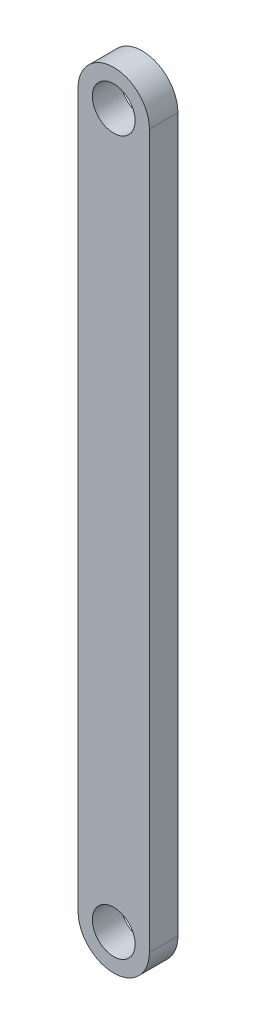
from build123d import *

# Parameters (mm, degrees)
Y_KSEKLIK_EKSTR_ZYON1_DEPTH = 2
IZIM3_R                     = 1.5
KES_EKSTR_ZYON1_DEPTH       = 3
IZIM5_R                     = 1.5
KES_EKSTR_ZYON2_DEPTH       = 2


with BuildPart() as part:
    # Çizim1 → Yükseklik-Ekstrüzyon1 (new body)
    with BuildSketch(Plane.XY):
        with BuildLine():
            Line((-2.5, 50), (-2.5, 0))
            ThreePointArc((-2.5, 0), (0, -2.5), (2.5, 0))
            Line((2.5, 0), (2.5, 50))
            ThreePointArc((2.5, 50), (0, 52.5), (-2.5, 50))
        make_face()
    extrude(amount=-Y_KSEKLIK_EKSTR_ZYON1_DEPTH)

    # Çizim3 → Kes-Ekstrüzyon1 (cut, through all)
    with BuildSketch(Plane.XY):
        Circle(IZIM3_R)
    extrude(amount=-KES_EKSTR_ZYON1_DEPTH, mode=Mode.SUBTRACT)

    # Çizim5 → Kes-Ekstrüzyon2 (cut)
    with BuildSketch(Plane.XY):
        with Locations((0, 50)):
            Circle(IZIM5_R)
    extrude(amount=-KES_EKSTR_ZYON2_DEPTH, mode=Mode.SUBTRACT)


solid = part.part
